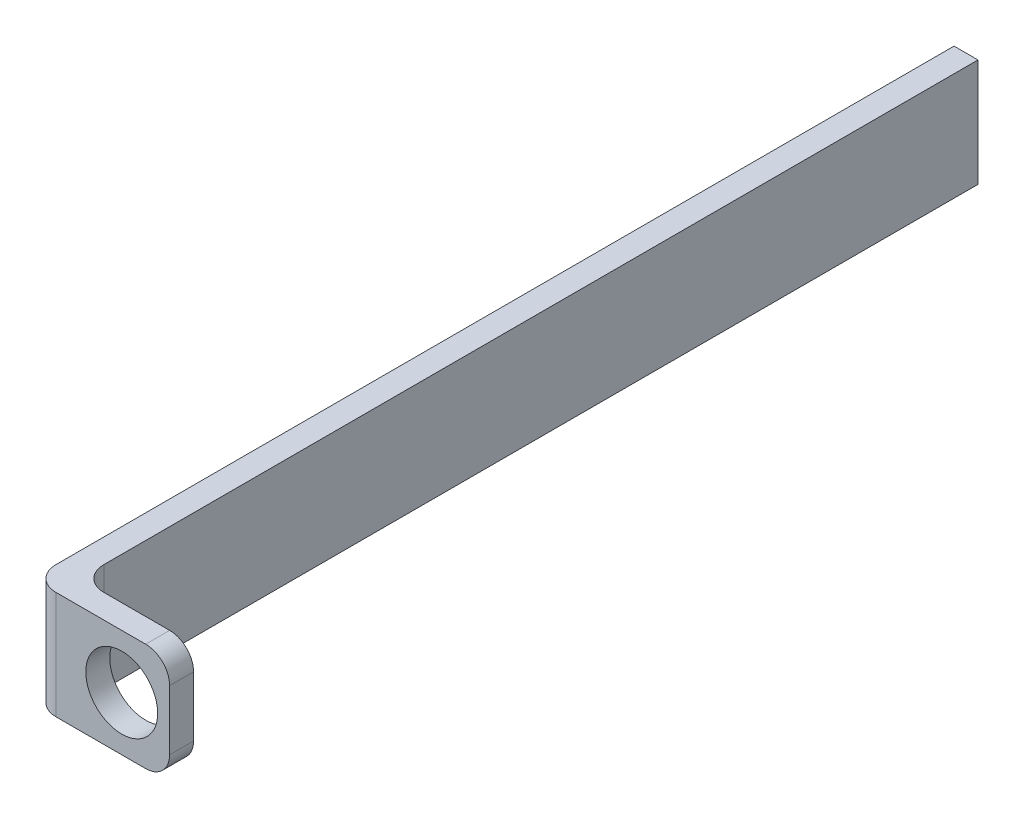
from build123d import *

# Parameters (mm, degrees)
SKETCH1_R           = 3
BOSS_EXTRUDE1_DEPTH = 2
SKETCH2_W           = 2
SKETCH2_H           = 9
BOSS_EXTRUDE2_DEPTH = 75
FILLET1_R           = 2


with BuildPart() as part:
    # Sketch1 → Boss-Extrude1 (new body)
    with BuildSketch(Plane.XY):
        with BuildLine():
            Line((-7.5, 4.5), (2, 4.5))
            ThreePointArc((2, 4.5), (3.414213562, 3.914213562), (4, 2.5))
            Line((4, 2.5), (4, -2.5))
            ThreePointArc((4, -2.5), (3.414213562, -3.914213562), (2, -4.5))
            Line((2, -4.5), (-7.5, -4.5))
            Line((-7.5, -4.5), (-7.5, 4.5))
        make_face()
        Circle(SKETCH1_R, mode=Mode.SUBTRACT)
    extrude(amount=BOSS_EXTRUDE1_DEPTH)

    # Sketch2 → Boss-Extrude2 (add)
    with BuildSketch(Plane(origin=(0, 0, 0), x_dir=(-1, 0, 0), z_dir=(0, 0, -1))):
        with Locations((6.5, 0)):
            Rectangle(SKETCH2_W, SKETCH2_H)
    extrude(amount=BOSS_EXTRUDE2_DEPTH)

    # Fillet1
    fillet1_edges = [part.edges().sort_by_distance(p)[0] for p in [
        (-5.5, 0, 0),
        (-7.5, 0, 2),
    ]]
    fillet(fillet1_edges, radius=FILLET1_R)


solid = part.part
